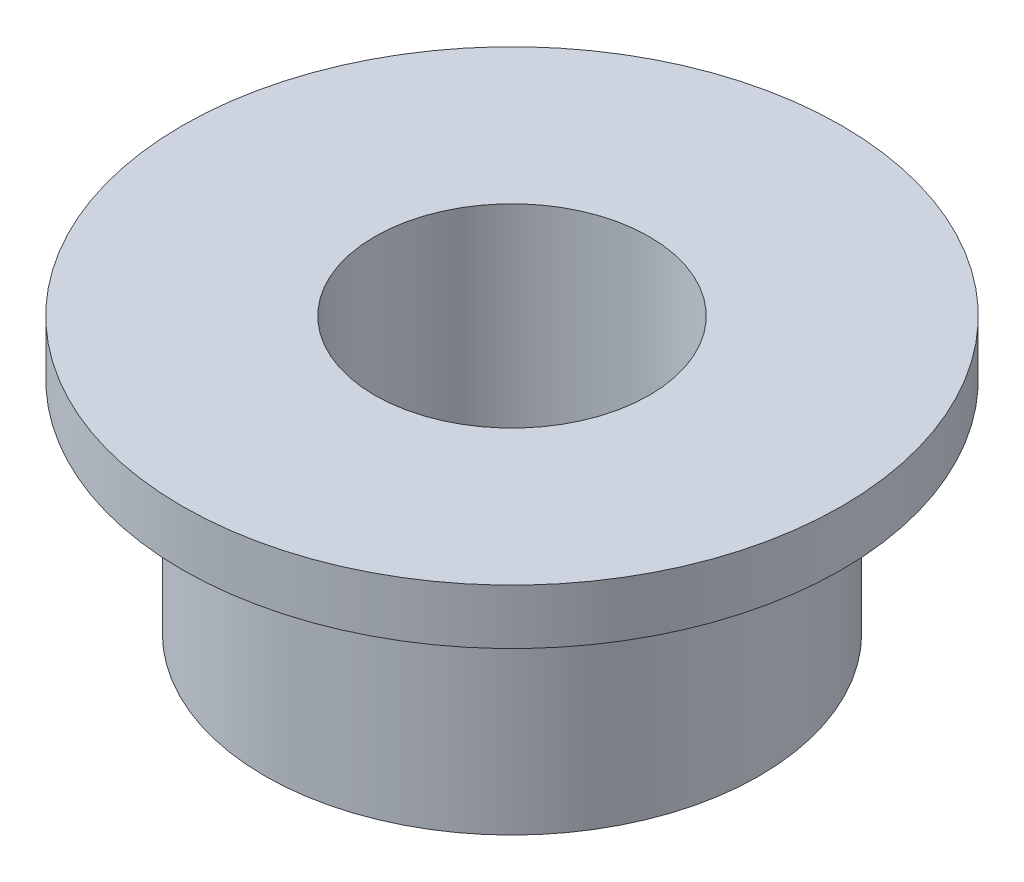
from build123d import *


with BuildPart() as part:
    # Sketch1 → Revolve1 (revolve)
    with BuildSketch(Plane(origin=(0, 0, 0), x_dir=(0, 0, -1), z_dir=(1, 0, 0))):
        Polygon((25, 0), (25, 50), (60, 50), (60, 40), (45, 40), (45, 0), align=None)
    revolve(axis=Axis((0, 0, 0), (0, 1, 0)))


solid = part.part
